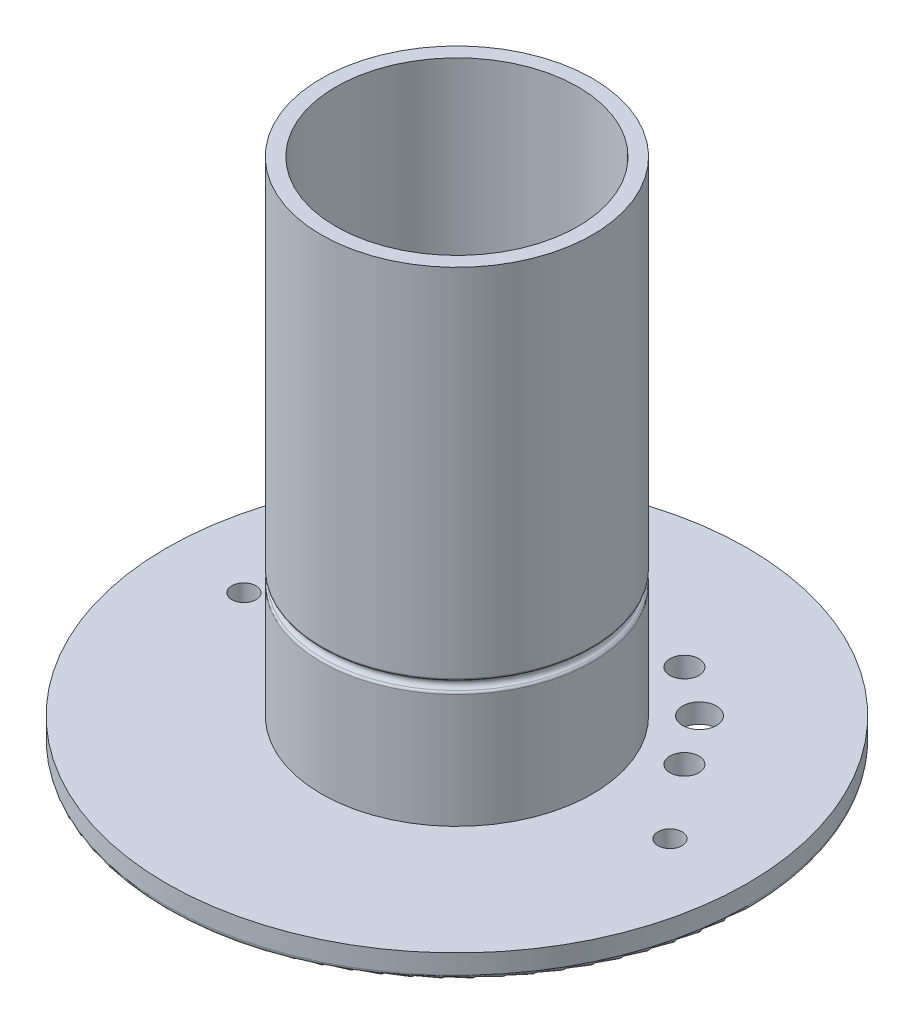
from build123d import *

# Parameters (mm, degrees)
SKETCH1_R           = 60
BOSS_EXTRUDE1_DEPTH = 5
SKETCH2_R           = 2.5
CUT_EXTRUDE1_DEPTH  = 5
SKETCH3_R           = 28
BOSS_EXTRUDE2_DEPTH = 100
SKETCH5_R           = 25
CUT_EXTRUDE3_DEPTH  = 105
SKETCH7_R           = 1
FILLET2_R           = 1
FILLET3_R           = 0.5
FILLET4_R           = 0.5
SKETCH9_R           = 3.5
SKETCH9_R_2         = 3
CUT_EXTRUDE4_DEPTH  = 5
SKETCH10_R          = 5
CUT_EXTRUDE6_DEPTH  = 1
SKETCH11_R          = 5
CUT_EXTRUDE7_DEPTH  = 2


with BuildPart() as part:
    # Sketch1 → Boss-Extrude1 (new body)
    with BuildSketch(Plane(origin=(0, 0, 0), x_dir=(1, 0, 0), z_dir=(0, 1, 0))):
        with Locations(Location((0, 0, 0), (0, 0, 270))):
            Circle(SKETCH1_R)
    extrude(amount=BOSS_EXTRUDE1_DEPTH)

    # Sketch2 → Cut-Extrude1 (cut)
    with BuildSketch(Plane(origin=(0, 5, 0), x_dir=(1, 0, 0), z_dir=(0, 1, 0))):
        with Locations(Location((-44, 0, 0), (0, 0, 270))):
            Circle(SKETCH2_R)
        with Locations(Location((44, 0, 0), (0, 0, 270))):
            Circle(SKETCH2_R)
    extrude(amount=-CUT_EXTRUDE1_DEPTH, mode=Mode.SUBTRACT)

    # Sketch3 → Boss-Extrude2 (add)
    with BuildSketch(Plane(origin=(0, 5, 0), x_dir=(1, 0, 0), z_dir=(0, 1, 0))):
        with Locations(Location((0, 0, 0), (0, 0, 270))):
            Circle(SKETCH3_R)
    extrude(amount=BOSS_EXTRUDE2_DEPTH)

    # Sketch5 → Cut-Extrude3 (cut)
    with BuildSketch(Plane(origin=(0, 105, 0), x_dir=(1, 0, 0), z_dir=(0, 1, 0))):
        with Locations(Location((0, 0, 0), (0, 0, 270))):
            Circle(SKETCH5_R)
    extrude(amount=-CUT_EXTRUDE3_DEPTH, mode=Mode.SUBTRACT)

    # Sketch7 → Cut-Revolve1 (revolve, cut)
    with BuildSketch(Plane(origin=(0, 0, 0), x_dir=(0, 0, -1), z_dir=(1, 0, 0)), mode=Mode.PRIVATE) as cut_revolve1_sk:
        with Locations((28, 30)):
            Circle(SKETCH7_R)
    revolve(cut_revolve1_sk.sketch.rotate(Axis((0, 105, 0), (0, -1, 0)), 180), axis=Axis((0, 105, 0), (0, -1, 0)), mode=Mode.SUBTRACT)

    # Fillet2
    fillet2_edges = [part.edges().sort_by_distance(p)[0] for p in [
        (0, 0, -60),
    ]]
    fillet(fillet2_edges, radius=FILLET2_R)

    # Fillet3
    fillet3_edges = [part.edges().sort_by_distance(p)[0] for p in [
        (0, 29, -28),
    ]]
    fillet(fillet3_edges, radius=FILLET3_R)

    # Fillet4
    fillet4_edges = [part.edges().sort_by_distance(p)[0] for p in [
        (0, 31, -28),
    ]]
    fillet(fillet4_edges, radius=FILLET4_R)

    # Sketch9 → Cut-Extrude4 (cut)
    with BuildSketch(Plane.XZ):
        with Locations(Location((-25.050313714, -25.050138973, 0), (0, 0, 270))):
            Circle(SKETCH9_R)
        with Locations(Location((25.052056005, -25.047802603, 0), (0, 0, 270))):
            Circle(SKETCH9_R)
        with Locations(Location((32.191989922, -14.787620166, 0), (0, 0, 270))):
            Circle(SKETCH9_R_2)
        with Locations(Location((14.793086054, -32.189478566, 0), (0, 0, 270))):
            Circle(SKETCH9_R_2)
        with Locations(Location((-14.79053384, -32.190651346, 0), (0, 0, 270))):
            Circle(SKETCH9_R_2)
        with Locations(Location((-32.191989922, -14.787620166, 0), (0, 0, 270))):
            Circle(SKETCH9_R_2)
    extrude(amount=-CUT_EXTRUDE4_DEPTH, mode=Mode.SUBTRACT)

    # Sketch10 → Cut-Extrude6 (cut)
    with BuildSketch(Plane.XZ):
        with Locations(Location((-25.050313714, -25.050138973, 0), (0, 0, 270))):
            Circle(SKETCH10_R)
        with Locations(Location((25.052056005, -25.047802603, 0), (0, 0, 270))):
            Circle(SKETCH10_R)
    extrude(amount=-CUT_EXTRUDE6_DEPTH, mode=Mode.SUBTRACT)

    # Sketch11 → Cut-Extrude7 (cut)
    with BuildSketch(Plane.XZ):
        with Locations(Location((-32.191989922, -14.787620166, 0), (0, 0, 270))):
            Circle(SKETCH11_R)
        with Locations(Location((-14.79053384, -32.190651346, 0), (0, 0, 270))):
            Circle(SKETCH11_R)
    extrude(amount=-CUT_EXTRUDE7_DEPTH, mode=Mode.SUBTRACT)


solid = part.part
